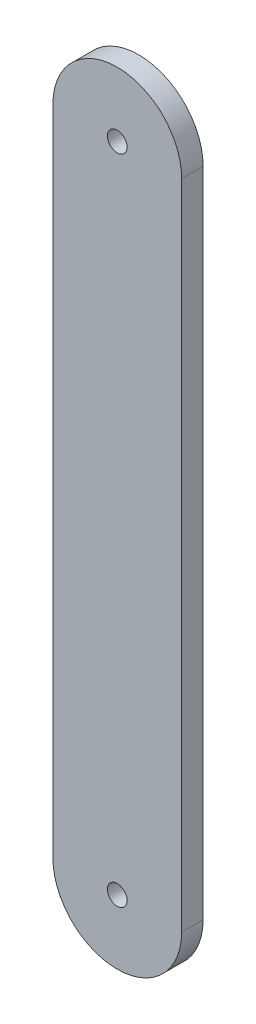
from build123d import *

# Parameters (mm, degrees)
SKETCH1_R           = 1.4605
BOSS_EXTRUDE1_DEPTH = 3.175


with BuildPart() as part:
    # Sketch1 → Boss-Extrude1 (new body)
    with BuildSketch(Plane.XY):
        with BuildLine():
            Line((-19.353012887, 0), (-19.353012887, 96.52))
            ThreePointArc((-19.353012887, 96.52), (-9.828012887, 106.045), (-0.303012887, 96.52))
            Line((-0.303012887, 96.52), (-0.303012887, 0))
            ThreePointArc((-0.303012887, 0), (-9.828012887, -9.525), (-19.353012887, 0))
        make_face()
        with Locations((-9.828012887, 0)):
            Circle(SKETCH1_R, mode=Mode.SUBTRACT)
        with Locations((-9.828012887, 96.52)):
            Circle(SKETCH1_R, mode=Mode.SUBTRACT)
    extrude(amount=BOSS_EXTRUDE1_DEPTH)


solid = part.part
